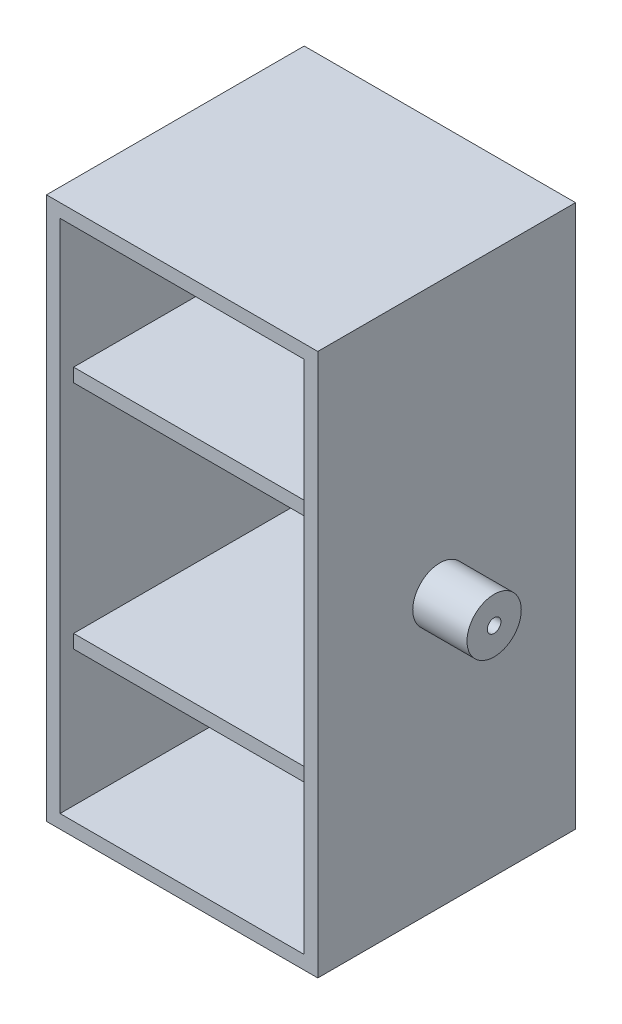
from build123d import *

# Parameters (mm, degrees)
SKETCH2_W           = 100
SKETCH2_H           = 100
BOSS_EXTRUDE1_DEPTH = 200
SHELL3_T            = -5
SKETCH3_W           = 90
SKETCH3_H           = 5
BOSS_EXTRUDE2_DEPTH = 85
SKETCH4_R           = 10
SKETCH4_R_2         = 2.5
BOSS_EXTRUDE3_DEPTH = 20
SKETCH5_R           = 10
SKETCH5_R_2         = 2.5
BOSS_EXTRUDE4_DEPTH = 20
SKETCH7_W           = 90
SKETCH7_H           = 5
CUT_EXTRUDE1_DEPTH  = 5


with BuildPart() as part:
    # Sketch2 → Boss-Extrude1 (new body)
    with BuildSketch(Plane(origin=(0, 0, 0), x_dir=(1, 0, 0), z_dir=(0, 1, 0))):
        with Locations((50, -50)):
            Rectangle(SKETCH2_W, SKETCH2_H)
    extrude(amount=BOSS_EXTRUDE1_DEPTH)

    # Shell3
    shell3_openings = [part.faces().sort_by_distance(p)[0] for p in [
        (50, 100, 100),
    ]]
    offset(amount=SHELL3_T, openings=shell3_openings, kind=Kind.INTERSECTION)

    # Sketch3 → Boss-Extrude2 (add)
    with BuildSketch(Plane.XY.offset(5)):
        with Locations((50, 57.5)):
            Rectangle(SKETCH3_W, SKETCH3_H)
        with Locations((50, 142.5)):
            Rectangle(SKETCH3_W, SKETCH3_H)
    extrude(amount=BOSS_EXTRUDE2_DEPTH)

    # Sketch4 → Boss-Extrude3 (add)
    with BuildSketch(Plane(origin=(100, 0, 0), x_dir=(0, 0, -1), z_dir=(1, 0, 0))):
        with Locations((-50, 100)):
            Circle(SKETCH4_R)
        with Locations((-50, 100)):
            Circle(SKETCH4_R_2, mode=Mode.SUBTRACT)
    extrude(amount=BOSS_EXTRUDE3_DEPTH)

    # Sketch5 → Boss-Extrude4 (add)
    with BuildSketch(Plane.ZY):
        with Locations((50, 100)):
            Circle(SKETCH5_R)
        with Locations((50, 100)):
            Circle(SKETCH5_R_2, mode=Mode.SUBTRACT)
    extrude(amount=BOSS_EXTRUDE4_DEPTH)

    # Sketch7 → Cut-Extrude1 (cut)
    with BuildSketch(Plane.XY.offset(100)):
        Polygon((95, 200), (0, 200), (0, 195), (5, 195), (95, 195), align=None)
        Polygon((100, 200), (95, 200), (95, 195), (95, 5), (95, 0), (100, 0), align=None)
        Polygon((5, 195), (0, 195), (0, 0), (5, 0), (5, 5), align=None)
        with Locations((50, 2.5)):
            Rectangle(SKETCH7_W, SKETCH7_H)
    extrude(amount=-CUT_EXTRUDE1_DEPTH, mode=Mode.SUBTRACT)


solid = part.part
